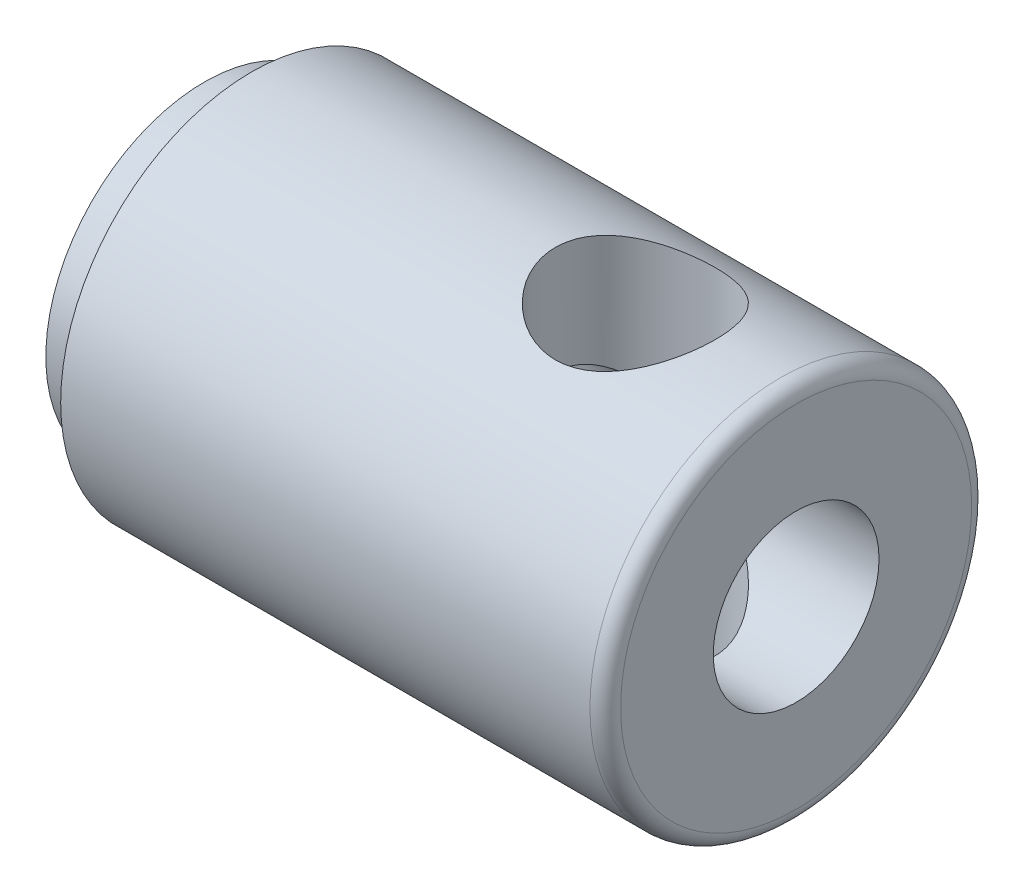
from build123d import *

# Parameters (mm, degrees)
SKETCH2_R               = 1.984375
CUT_EXTRUDE1_DEPTH      = 5.7371001
CUT_EXTRUDE1_DEPTH_BACK = 5.7371001


with BuildPart() as part:
    # Sketch1 → Revolve1 (revolve)
    with BuildSketch(Plane.XY):
        with BuildLine():
            Line((0, 2.0574), (-12.931775, 2.0574))
            Line((-12.931775, 2.0574), (-14.684375, 3.81))
            Line((-14.684375, 3.81), (-14.684375, 3.937))
            Line((-14.684375, 3.937), (-13.515975, 3.937))
            Line((-13.515975, 3.937), (-13.515975, 4.7371))
            Line((-13.515975, 4.7371), (-0.381, 4.7371))
            ThreePointArc((-0.381, 4.7371), (-0.111592316, 4.625507684), (0, 4.3561))
            Line((0, 4.3561), (0, 2.0574))
        make_face()
    revolve(axis=Axis((0, 0, 0), (-1, 0, 0)))

    # Sketch2 → Cut-Extrude1 (cut, two sides)
    with BuildSketch(Plane(origin=(0, 0, 0), x_dir=(1, 0, 0), z_dir=(0, 1, 0))) as cut_extrude1_sk:
        with Locations((-3.990975, 0)):
            Circle(SKETCH2_R)
    extrude(amount=CUT_EXTRUDE1_DEPTH, mode=Mode.SUBTRACT)
    extrude(cut_extrude1_sk.sketch, amount=-CUT_EXTRUDE1_DEPTH_BACK, mode=Mode.SUBTRACT)


solid = part.part
